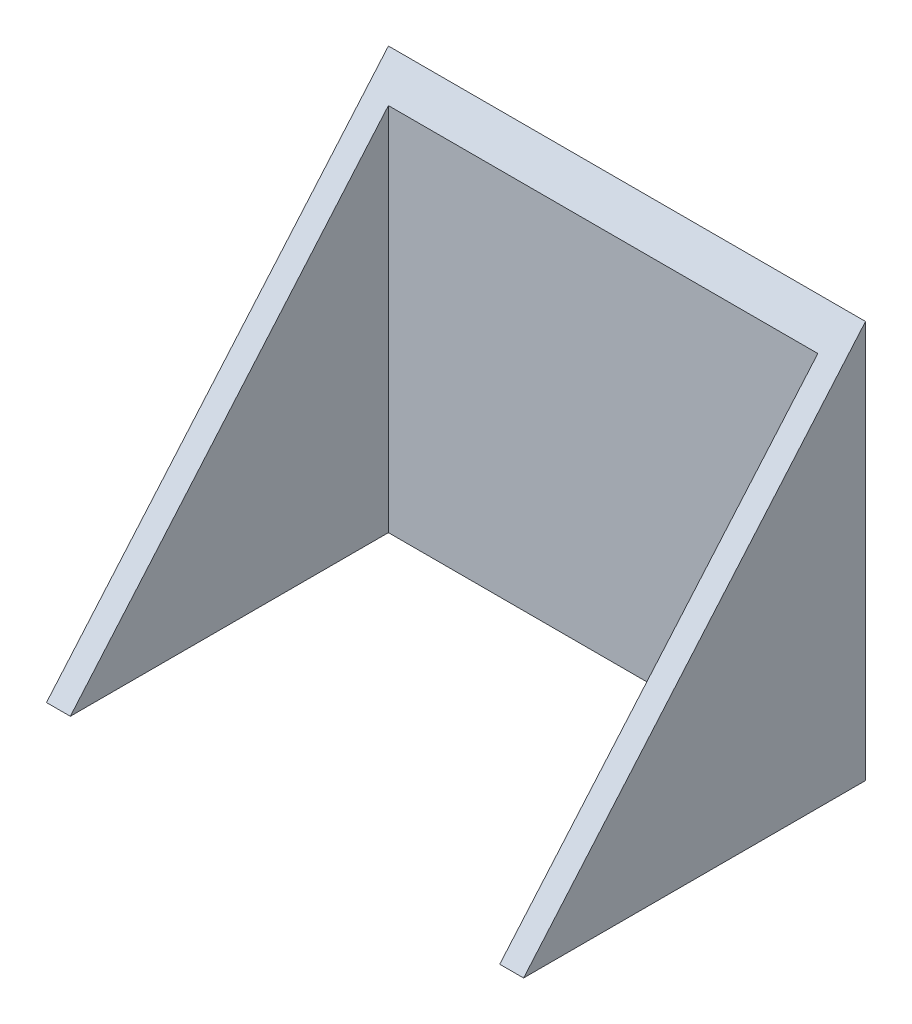
from build123d import *

# Parameters (mm, degrees)
SKETCH1_W           = 6
SKETCH1_H           = 80
SKETCH1_W_2         = 120
SKETCH1_H_2         = 6
BOSS_EXTRUDE1_DEPTH = 100
CUT_EXTRUDE1_DEPTH  = 120


with BuildPart() as part:
    # Sketch1 → Boss-Extrude1 (new body)
    with BuildSketch(Plane(origin=(0, 0, 0), x_dir=(1, 0, 0), z_dir=(0, 1, 0))):
        with Locations((57, -43)):
            Rectangle(SKETCH1_W, SKETCH1_H)
        Rectangle(SKETCH1_W_2, SKETCH1_H_2)
        with Locations((-57, -43)):
            Rectangle(SKETCH1_W, SKETCH1_H)
    extrude(amount=BOSS_EXTRUDE1_DEPTH)

    # Sketch2 → Cut-Extrude1 (cut)
    with BuildSketch(Plane.ZY.offset(60)):
        Polygon((83, 0), (-3, 100), (83, 100), align=None)
    extrude(amount=-CUT_EXTRUDE1_DEPTH, mode=Mode.SUBTRACT)


solid = part.part
